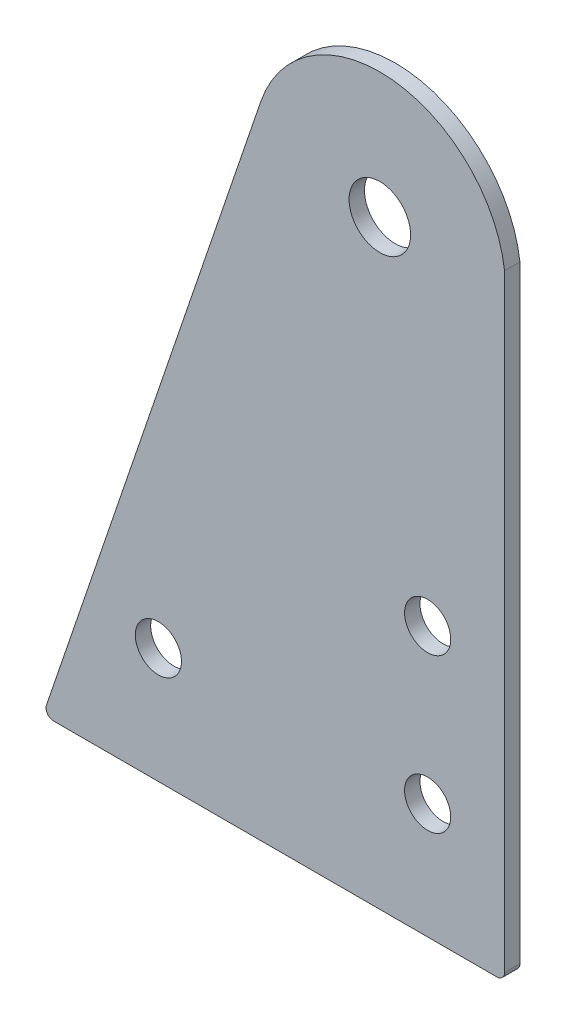
from build123d import *

# Parameters (mm, degrees)
EXTRUDE_1_DEPTH     = 2
FILLET_1_R          = 1
SKETCH_2_R          = 4
SKETCH_2_R_2        = 3
CUT_EXTRUDE_1_DEPTH = 2


with BuildPart() as part:
    # 草图1 → 凸台-拉伸1 (new body)
    with BuildSketch(Plane.XY):
        with BuildLine():
            Line((-60, 0), (0, 0))
            Line((0, 0), (0, 75.862592271))
            Line((0, 75.862592271), (0, 80))
            ThreePointArc((0, 80), (-14.574173945, 94.195139291), (-31.689992774, 83.197081668))
            Line((-31.689992774, 83.197081668), (-60, 0))
        make_face()
    extrude(amount=EXTRUDE_1_DEPTH)

    # 圆角1
    fillet_1_edges = [part.edges().sort_by_distance(p)[0] for p in [
        (0, 0, 1),
        (-60, 0, 1),
    ]]
    fillet(fillet_1_edges, radius=FILLET_1_R)

    # 草图2 → 切除-拉伸1 (cut)
    with BuildSketch(Plane.XY.offset(2)):
        with Locations((-16.214970621, 77.931296136)):
            Circle(SKETCH_2_R)
        with Locations((-10, 35)):
            Circle(SKETCH_2_R_2)
        with Locations((-10, 15)):
            Circle(SKETCH_2_R_2)
        with Locations((-45, 15)):
            Circle(SKETCH_2_R_2)
    extrude(amount=-CUT_EXTRUDE_1_DEPTH, mode=Mode.SUBTRACT)


solid = part.part
